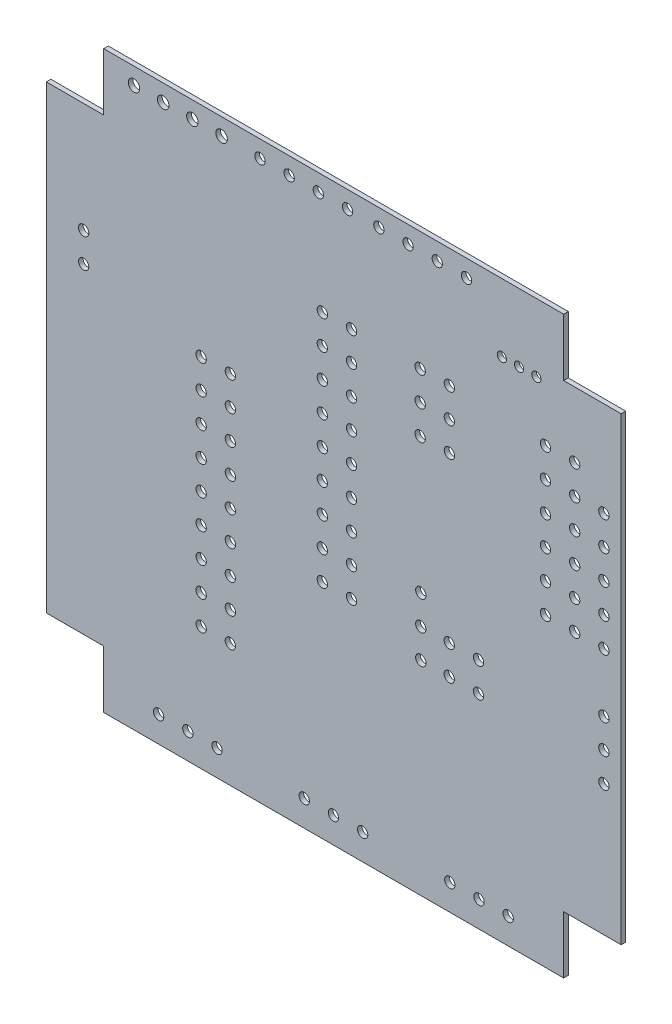
from build123d import *

# Parameters (mm, degrees)
SKETCH_1_R      = 0.4499991
SKETCH_1_R_2    = 0.3999992
SKETCH_1_R_3    = 0.499999
EXTRUDE_1_DEPTH = 0.40132


with BuildPart() as part:
    # Эскиз1 → Бобышка-Вытянуть1 (new body)
    with BuildSketch(Plane(origin=(0, 0, 0), x_dir=(-1, 0, 0), z_dir=(0, 0, -1))):
        Polygon((-49.98924216, 4.97417344), (-44.989242, 4.97417344), (-44.989242, -0.02582672), (-4.98924326, -0.02582672), (-4.98924326, 4.97417344), (0.0107569, 4.97417344), (0.0107569, 44.97417472), (-4.98924326, 44.97417472), (-4.98924326, 49.97417488), (-44.989242, 49.97417488), (-44.989242, 44.97417472), (-49.98924216, 44.97417472), align=None)
        with Locations((-48.4892604, 36.7241836)):
            Circle(SKETCH_1_R, mode=Mode.SUBTRACT)
        with Locations((-45.9492604, 39.2741912)):
            Circle(SKETCH_1_R, mode=Mode.SUBTRACT)
        with Locations((-45.9492604, 36.7241836)):
            Circle(SKETCH_1_R, mode=Mode.SUBTRACT)
        with Locations((-42.6142404, 44.0741816)):
            Circle(SKETCH_1_R_2, mode=Mode.SUBTRACT)
        with Locations((-41.114218, 44.0741816)):
            Circle(SKETCH_1_R_2, mode=Mode.SUBTRACT)
        with Locations((-43.4092604, 39.2741912)):
            Circle(SKETCH_1_R, mode=Mode.SUBTRACT)
        with Locations((-48.4892604, 34.174176)):
            Circle(SKETCH_1_R, mode=Mode.SUBTRACT)
        with Locations((-45.9492604, 34.174176)):
            Circle(SKETCH_1_R, mode=Mode.SUBTRACT)
        with Locations((-48.4892604, 31.6241684)):
            Circle(SKETCH_1_R, mode=Mode.SUBTRACT)
        with Locations((-43.4092604, 34.174176)):
            Circle(SKETCH_1_R, mode=Mode.SUBTRACT)
        with Locations((-43.4092604, 36.7241836)):
            Circle(SKETCH_1_R, mode=Mode.SUBTRACT)
        with Locations((-45.9492604, 31.6241684)):
            Circle(SKETCH_1_R, mode=Mode.SUBTRACT)
        with Locations((-39.6142464, 44.0741816)):
            Circle(SKETCH_1_R_2, mode=Mode.SUBTRACT)
        with Locations((-36.5392208, 48.4741728)):
            Circle(SKETCH_1_R, mode=Mode.SUBTRACT)
        with Locations((-35.052, 39.624)):
            Circle(SKETCH_1_R, mode=Mode.SUBTRACT)
        with Locations((-31.4592208, 48.4741728)):
            Circle(SKETCH_1_R, mode=Mode.SUBTRACT)
        with Locations((-28.9192208, 48.4741728)):
            Circle(SKETCH_1_R, mode=Mode.SUBTRACT)
        with Locations((-33.9992208, 48.4741728)):
            Circle(SKETCH_1_R, mode=Mode.SUBTRACT)
        with Locations((-35.052, 37.084)):
            Circle(SKETCH_1_R, mode=Mode.SUBTRACT)
        with Locations((-32.512, 39.624)):
            Circle(SKETCH_1_R, mode=Mode.SUBTRACT)
        with Locations((-35.052, 34.544)):
            Circle(SKETCH_1_R, mode=Mode.SUBTRACT)
        with Locations((-32.512, 34.544)):
            Circle(SKETCH_1_R, mode=Mode.SUBTRACT)
        with Locations((-32.512, 37.084)):
            Circle(SKETCH_1_R, mode=Mode.SUBTRACT)
        with Locations((-26.543, 34.544)):
            Circle(SKETCH_1_R, mode=Mode.SUBTRACT)
        with Locations((-48.4892604, 29.0741608)):
            Circle(SKETCH_1_R, mode=Mode.SUBTRACT)
        with Locations((-45.9492604, 29.0741608)):
            Circle(SKETCH_1_R, mode=Mode.SUBTRACT)
        with Locations((-48.4892604, 26.5241532)):
            Circle(SKETCH_1_R, mode=Mode.SUBTRACT)
        with Locations((-43.4092604, 29.0741608)):
            Circle(SKETCH_1_R, mode=Mode.SUBTRACT)
        with Locations((-43.4092604, 31.6241684)):
            Circle(SKETCH_1_R, mode=Mode.SUBTRACT)
        with Locations((-45.9492604, 26.5241532)):
            Circle(SKETCH_1_R, mode=Mode.SUBTRACT)
        with Locations((-48.4892604, 18.8841888)):
            Circle(SKETCH_1_R, mode=Mode.SUBTRACT)
        with Locations((-48.4892604, 21.4241888)):
            Circle(SKETCH_1_R, mode=Mode.SUBTRACT)
        with Locations((-48.4892604, 16.3441888)):
            Circle(SKETCH_1_R, mode=Mode.SUBTRACT)
        with Locations((-43.4092604, 26.5241532)):
            Circle(SKETCH_1_R, mode=Mode.SUBTRACT)
        with Locations((-40.1692872, 2.2241764)):
            Circle(SKETCH_1_R, mode=Mode.SUBTRACT)
        with Locations((-37.6292872, 2.2241764)):
            Circle(SKETCH_1_R, mode=Mode.SUBTRACT)
        with Locations((-35.0393508, 20.234148)):
            Circle(SKETCH_1_R, mode=Mode.SUBTRACT)
        with Locations((-32.5642732, 22.774148)):
            Circle(SKETCH_1_R, mode=Mode.SUBTRACT)
        with Locations((-37.5893584, 20.234148)):
            Circle(SKETCH_1_R, mode=Mode.SUBTRACT)
        with Locations((-26.543, 24.384)):
            Circle(SKETCH_1_R, mode=Mode.SUBTRACT)
        with Locations((-26.543, 29.464)):
            Circle(SKETCH_1_R, mode=Mode.SUBTRACT)
        with Locations((-26.543, 21.844)):
            Circle(SKETCH_1_R, mode=Mode.SUBTRACT)
        with Locations((-37.5893584, 17.694148)):
            Circle(SKETCH_1_R, mode=Mode.SUBTRACT)
        with Locations((-35.0393508, 17.694148)):
            Circle(SKETCH_1_R, mode=Mode.SUBTRACT)
        with Locations((-35.0892872, 2.2241764)):
            Circle(SKETCH_1_R, mode=Mode.SUBTRACT)
        with Locations((-32.5642732, 17.694148)):
            Circle(SKETCH_1_R, mode=Mode.SUBTRACT)
        with Locations((-32.5642732, 20.234148)):
            Circle(SKETCH_1_R, mode=Mode.SUBTRACT)
        with Locations((-27.5067776, 2.2241764)):
            Circle(SKETCH_1_R, mode=Mode.SUBTRACT)
        with Locations((-26.543, 39.624)):
            Circle(SKETCH_1_R, mode=Mode.SUBTRACT)
        with Locations((-26.1942072, 48.4891588)):
            Circle(SKETCH_1_R, mode=Mode.SUBTRACT)
        with Locations((-26.543, 37.084)):
            Circle(SKETCH_1_R, mode=Mode.SUBTRACT)
        with Locations((-24.003, 39.624)):
            Circle(SKETCH_1_R, mode=Mode.SUBTRACT)
        with Locations((-23.6542072, 48.4891588)):
            Circle(SKETCH_1_R, mode=Mode.SUBTRACT)
        with Locations((-24.003, 37.084)):
            Circle(SKETCH_1_R, mode=Mode.SUBTRACT)
        with Locations((-26.543, 32.004)):
            Circle(SKETCH_1_R, mode=Mode.SUBTRACT)
        with Locations((-24.003, 32.004)):
            Circle(SKETCH_1_R, mode=Mode.SUBTRACT)
        with Locations((-26.543, 26.924)):
            Circle(SKETCH_1_R, mode=Mode.SUBTRACT)
        with Locations((-24.003, 29.464)):
            Circle(SKETCH_1_R, mode=Mode.SUBTRACT)
        with Locations((-24.003, 34.544)):
            Circle(SKETCH_1_R, mode=Mode.SUBTRACT)
        with Locations((-24.003, 26.924)):
            Circle(SKETCH_1_R, mode=Mode.SUBTRACT)
        with Locations((-21.1142072, 48.4891588)):
            Circle(SKETCH_1_R, mode=Mode.SUBTRACT)
        with Locations((-18.5742072, 48.4891588)):
            Circle(SKETCH_1_R, mode=Mode.SUBTRACT)
        with Locations((-15.24, 48.51399746)):
            Circle(SKETCH_1_R_3, mode=Mode.SUBTRACT)
        with Locations((-10.16, 48.51399746)):
            Circle(SKETCH_1_R_3, mode=Mode.SUBTRACT)
        with Locations((-7.62, 48.51399746)):
            Circle(SKETCH_1_R_3, mode=Mode.SUBTRACT)
        with Locations((-12.7, 48.51399746)):
            Circle(SKETCH_1_R_3, mode=Mode.SUBTRACT)
        with Locations((-16.002, 28.46399946)):
            Circle(SKETCH_1_R, mode=Mode.SUBTRACT)
        with Locations((-16.002, 31.00399946)):
            Circle(SKETCH_1_R, mode=Mode.SUBTRACT)
        with Locations((-13.462, 28.46399946)):
            Circle(SKETCH_1_R, mode=Mode.SUBTRACT)
        with Locations((-3.239262, 32.8741532)):
            Circle(SKETCH_1_R, mode=Mode.SUBTRACT)
        with Locations((-3.239262, 35.4141532)):
            Circle(SKETCH_1_R, mode=Mode.SUBTRACT)
        with Locations((-13.462, 31.00399946)):
            Circle(SKETCH_1_R, mode=Mode.SUBTRACT)
        with Locations((-24.003, 21.844)):
            Circle(SKETCH_1_R, mode=Mode.SUBTRACT)
        with Locations((-24.003, 24.384)):
            Circle(SKETCH_1_R, mode=Mode.SUBTRACT)
        with Locations((-26.543, 19.304)):
            Circle(SKETCH_1_R, mode=Mode.SUBTRACT)
        with Locations((-16.002, 23.38399946)):
            Circle(SKETCH_1_R, mode=Mode.SUBTRACT)
        with Locations((-16.002, 25.92399946)):
            Circle(SKETCH_1_R, mode=Mode.SUBTRACT)
        with Locations((-16.002, 20.84399946)):
            Circle(SKETCH_1_R, mode=Mode.SUBTRACT)
        with Locations((-24.9667776, 2.2241764)):
            Circle(SKETCH_1_R, mode=Mode.SUBTRACT)
        with Locations((-24.003, 19.304)):
            Circle(SKETCH_1_R, mode=Mode.SUBTRACT)
        with Locations((-22.4267776, 2.2241764)):
            Circle(SKETCH_1_R, mode=Mode.SUBTRACT)
        with Locations((-16.002, 15.76399946)):
            Circle(SKETCH_1_R, mode=Mode.SUBTRACT)
        with Locations((-16.002, 18.30399946)):
            Circle(SKETCH_1_R, mode=Mode.SUBTRACT)
        with Locations((-16.002, 13.22399946)):
            Circle(SKETCH_1_R, mode=Mode.SUBTRACT)
        with Locations((-13.462, 15.76399946)):
            Circle(SKETCH_1_R, mode=Mode.SUBTRACT)
        with Locations((-13.462, 18.30399946)):
            Circle(SKETCH_1_R, mode=Mode.SUBTRACT)
        with Locations((-13.462, 13.22399946)):
            Circle(SKETCH_1_R, mode=Mode.SUBTRACT)
        with Locations((-13.462, 23.38399946)):
            Circle(SKETCH_1_R, mode=Mode.SUBTRACT)
        with Locations((-13.462, 25.92399946)):
            Circle(SKETCH_1_R, mode=Mode.SUBTRACT)
        with Locations((-13.462, 20.84399946)):
            Circle(SKETCH_1_R, mode=Mode.SUBTRACT)
        with Locations((-16.002, 10.68399946)):
            Circle(SKETCH_1_R, mode=Mode.SUBTRACT)
        with Locations((-13.462, 10.68399946)):
            Circle(SKETCH_1_R, mode=Mode.SUBTRACT)
        with Locations((-14.844268, 2.2241764)):
            Circle(SKETCH_1_R, mode=Mode.SUBTRACT)
        with Locations((-9.764268, 2.2241764)):
            Circle(SKETCH_1_R, mode=Mode.SUBTRACT)
        with Locations((-12.304268, 2.2241764)):
            Circle(SKETCH_1_R, mode=Mode.SUBTRACT)
    extrude(amount=-EXTRUDE_1_DEPTH)


solid = part.part
